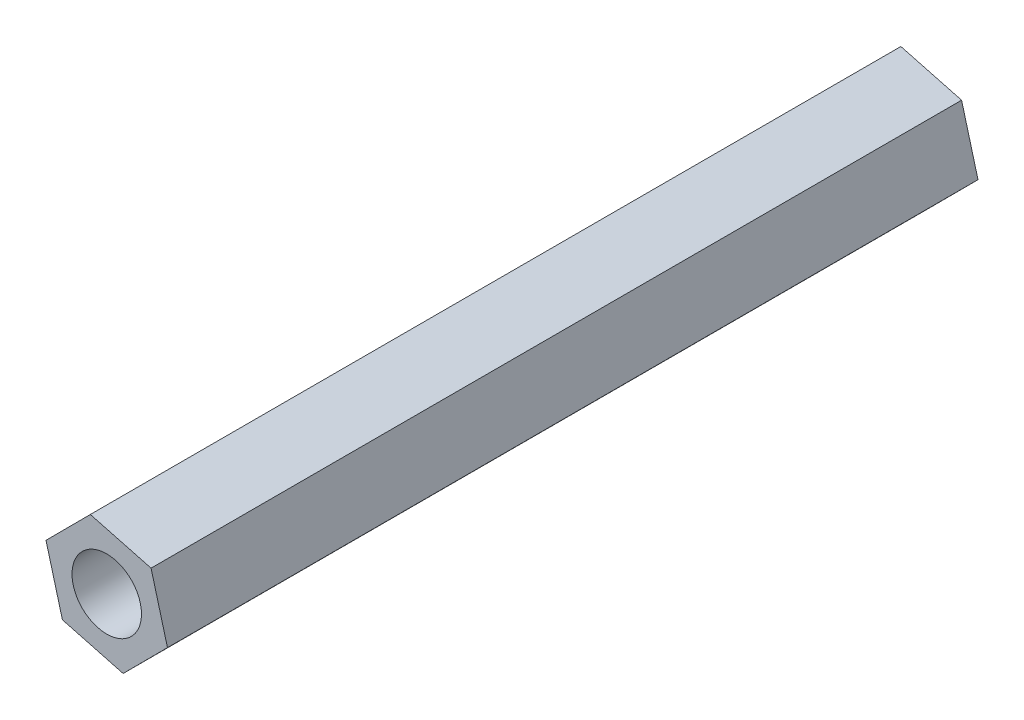
from build123d import *

# Parameters (mm, degrees)
SKETCH1_R           = 1.5
BOSS_EXTRUDE1_DEPTH = 35


with BuildPart() as part:
    # Sketch1 → Boss-Extrude1 (new body)
    with BuildSketch(Plane.XY):
        Polygon((1.91424692, 1.923276387), (-0.708482749, 2.619424656), (-2.62272967, 0.696148269), (-1.91424692, -1.923276387), (0.708482749, -2.619424656), (2.62272967, -0.696148269), align=None)
        Circle(SKETCH1_R, mode=Mode.SUBTRACT)
    extrude(amount=BOSS_EXTRUDE1_DEPTH)


solid = part.part
